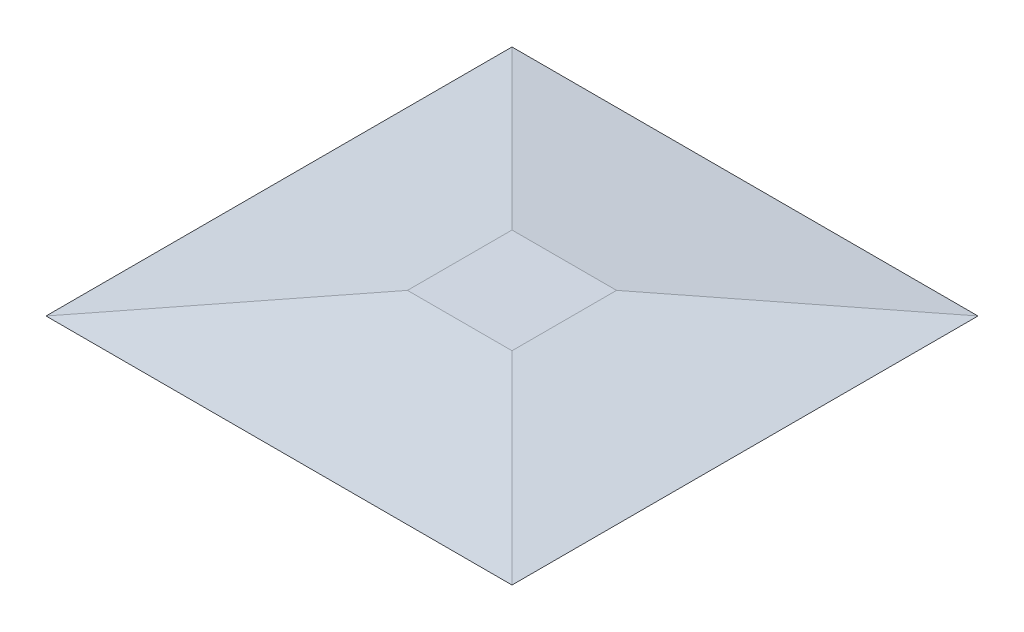
from build123d import *

# Parameters (mm, degrees)
CROQUIS1_W              = 53.34
CROQUIS1_H              = 53.34
SALIENTE_EXTRUIR1_DEPTH = 2.54
SALIENTE_EXTRUIR1_TAPER = 83


with BuildPart() as part:
    # Croquis1 → Saliente-Extruir1 (new body)
    with BuildSketch(Plane(origin=(0, 0, 0), x_dir=(1, 0, 0), z_dir=(0, 1, 0))):
        with Locations((-12.04802125, -2.64503335)):
            Rectangle(CROQUIS1_W, CROQUIS1_H)
    extrude(amount=SALIENTE_EXTRUIR1_DEPTH, taper=SALIENTE_EXTRUIR1_TAPER)


solid = part.part
